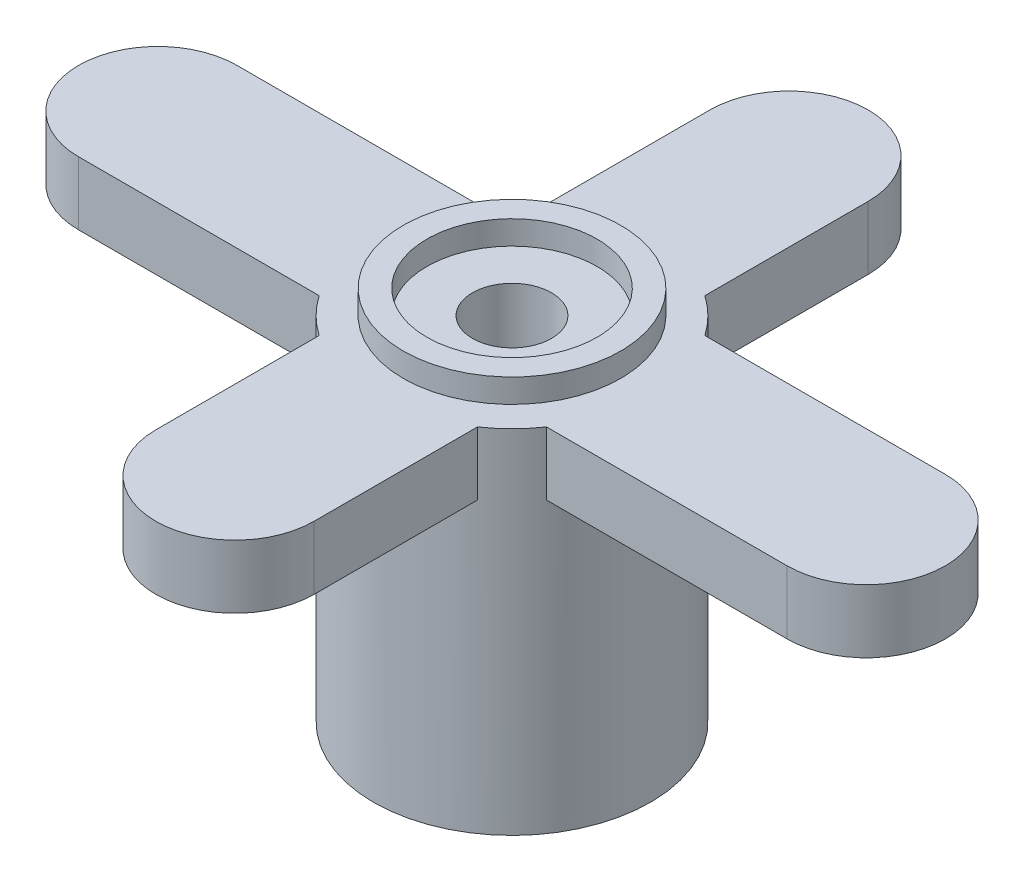
from build123d import *

# Parameters (mm, degrees)
SZKIC1_R                    = 3.5
DODANIE_WYCI_GNI_CIE1_DEPTH = 9.5
SZKIC2_R                    = 1.9
WYTNIJ_WYCI_GNI_CIE1_DEPTH  = 3.5
SZKIC3_R                    = 2
DODANIE_WYCI_GNI_CIE2_DEPTH = 1.6
WYTNIJ_WYCI_GNI_CIE2_START  = -0.6
SZKIC4_R                    = 2.15
WYTNIJ_WYCI_GNI_CIE2_DEPTH  = 0.6
SZKIC5_R                    = 1
WYTNIJ_WYCI_GNI_CIE3_DEPTH  = 31.6
SZKIC6_R                    = 3.5
SZKIC6_R_2                  = 2.75
WYTNIJ_WYCI_GNI_CIE4_DEPTH  = 0.6


with BuildPart() as part:
    # Szkic1 → Dodanie-wyciągnięcie1 (new body)
    with BuildSketch(Plane(origin=(0, 0, 0), x_dir=(1, 0, 0), z_dir=(0, 1, 0))):
        Circle(SZKIC1_R)
    extrude(amount=DODANIE_WYCI_GNI_CIE1_DEPTH)

    # Szkic2 → Wytnij-wyciągnięcie1 (cut)
    with BuildSketch(Plane.XZ):
        Circle(SZKIC2_R)
    extrude(amount=-WYTNIJ_WYCI_GNI_CIE1_DEPTH, mode=Mode.SUBTRACT)

    # Szkic3 → Dodanie-wyciągnięcie2 (add)
    with BuildSketch(Plane(origin=(0, 8.9, 0), x_dir=(1, 0, 0), z_dir=(0, 1, 0))):
        with Locations((-8.95, 0)):
            Circle(SZKIC3_R)
        with BuildLine():
            Line((-2, 2), (-8.95, 2))
            ThreePointArc((-8.95, 2), (-7.535786438, 1.414213562), (-6.95, 0))
            ThreePointArc((-6.95, 0), (-7.535786438, -1.414213562), (-8.95, -2))
            Line((-8.95, -2), (-2, -2))
            Line((-2, -2), (-2, 2))
        make_face()
        with Locations((0, 7)):
            Circle(SZKIC3_R)
        with BuildLine():
            Line((-2, 7), (-2, 2))
            Line((-2, 2), (0, 2))
            Line((0, 2), (2, 2))
            Line((2, 2), (2, 7))
            ThreePointArc((2, 7), (0, 5), (-2, 7))
        make_face()
        with BuildLine():
            Line((8.95, 2), (2, 2))
            Line((2, 2), (2, 0))
            Line((2, 0), (2, -2))
            Line((2, -2), (8.95, -2))
            ThreePointArc((8.95, -2), (6.95, 0), (8.95, 2))
        make_face()
        with Locations((8.95, 0)):
            Circle(SZKIC3_R)
        with Locations((0, -7)):
            Circle(SZKIC3_R)
        with BuildLine():
            Line((2, -2), (-2, -2))
            Line((-2, -2), (-2, -7))
            ThreePointArc((-2, -7), (0, -5), (2, -7))
            Line((2, -7), (2, -2))
        make_face()
    extrude(amount=-DODANIE_WYCI_GNI_CIE2_DEPTH)

    # Szkic4 → Wytnij-wyciągnięcie2 (cut)
    with BuildSketch(Plane(origin=(0, 9.5, 0), x_dir=(1, 0, 0), z_dir=(0, 1, 0)).offset(WYTNIJ_WYCI_GNI_CIE2_START)):
        Circle(SZKIC4_R)
    extrude(amount=WYTNIJ_WYCI_GNI_CIE2_DEPTH, mode=Mode.SUBTRACT)

    # Szkic5 → Wytnij-wyciągnięcie3 (cut)
    with BuildSketch(Plane(origin=(0, 8.9, 0), x_dir=(1, 0, 0), z_dir=(0, 1, 0))):
        Circle(SZKIC5_R)
    extrude(amount=-WYTNIJ_WYCI_GNI_CIE3_DEPTH, mode=Mode.SUBTRACT)

    # Szkic6 → Wytnij-wyciągnięcie4 (cut)
    with BuildSketch(Plane(origin=(0, 9.5, 0), x_dir=(1, 0, 0), z_dir=(0, 1, 0))):
        Circle(SZKIC6_R)
        Circle(SZKIC6_R_2, mode=Mode.SUBTRACT)
    extrude(amount=-WYTNIJ_WYCI_GNI_CIE4_DEPTH, mode=Mode.SUBTRACT)


solid = part.part
